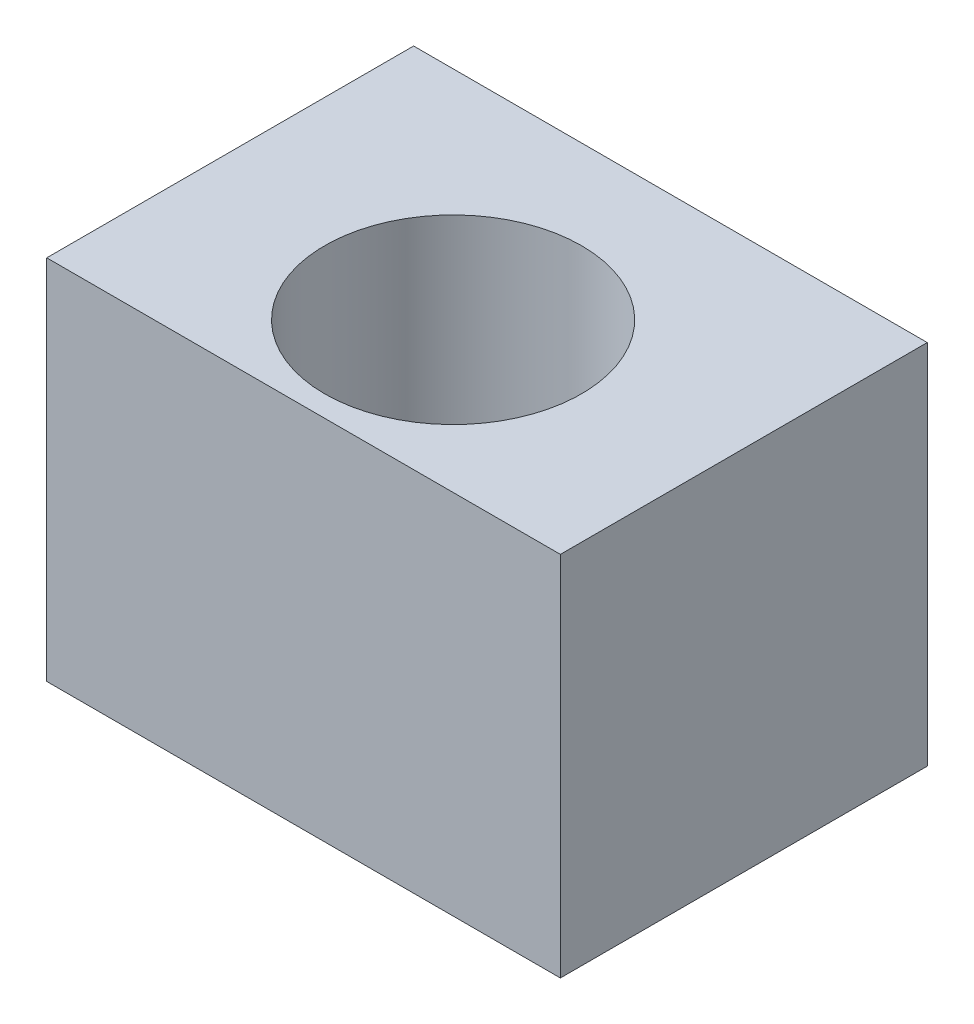
from build123d import *

# Parameters (mm, degrees)
SKETCH1_W                        = 7
SKETCH1_H                        = 5
BOSS_EXTRUDE1_DEPTH              = 5
F_3_0MM_DOWEL_HOLE1_D            = 3
F_3_0MM_DOWEL_HOLE1_DEPTH        = 1
CBORE_FOR_M1_6_SHCS1_D           = 1.7
CBORE_FOR_M1_6_SHCS1_DEPTH       = 5
CBORE_FOR_M1_6_SHCS1_CBORE_D     = 3.5
CBORE_FOR_M1_6_SHCS1_CBORE_DEPTH = 3


with BuildPart() as part:
    # Sketch1 → Boss-Extrude1 (new body)
    with BuildSketch(Plane(origin=(0, 0, 0), x_dir=(1, 0, 0), z_dir=(0, 1, 0))):
        Rectangle(SKETCH1_W, SKETCH1_H)
    extrude(amount=BOSS_EXTRUDE1_DEPTH)

    # Ø3.0mm Dowel Hole1
    with Locations(Plane(origin=(0, 0, -2.5), x_dir=(-1, 0, 0), z_dir=(0, 0, -1))):
        with Locations((0, 3.2)):
            Hole(F_3_0MM_DOWEL_HOLE1_D / 2, depth=F_3_0MM_DOWEL_HOLE1_DEPTH)

    # CBORE for M1.6 SHCS1
    with Locations(Plane(origin=(0, 5, 0), x_dir=(1, 0, 0), z_dir=(0, 1, 0))):
        with Locations((0, -0.461945314)):
            CounterBoreHole(CBORE_FOR_M1_6_SHCS1_D / 2, CBORE_FOR_M1_6_SHCS1_CBORE_D / 2, CBORE_FOR_M1_6_SHCS1_CBORE_DEPTH, depth=CBORE_FOR_M1_6_SHCS1_DEPTH)


solid = part.part
